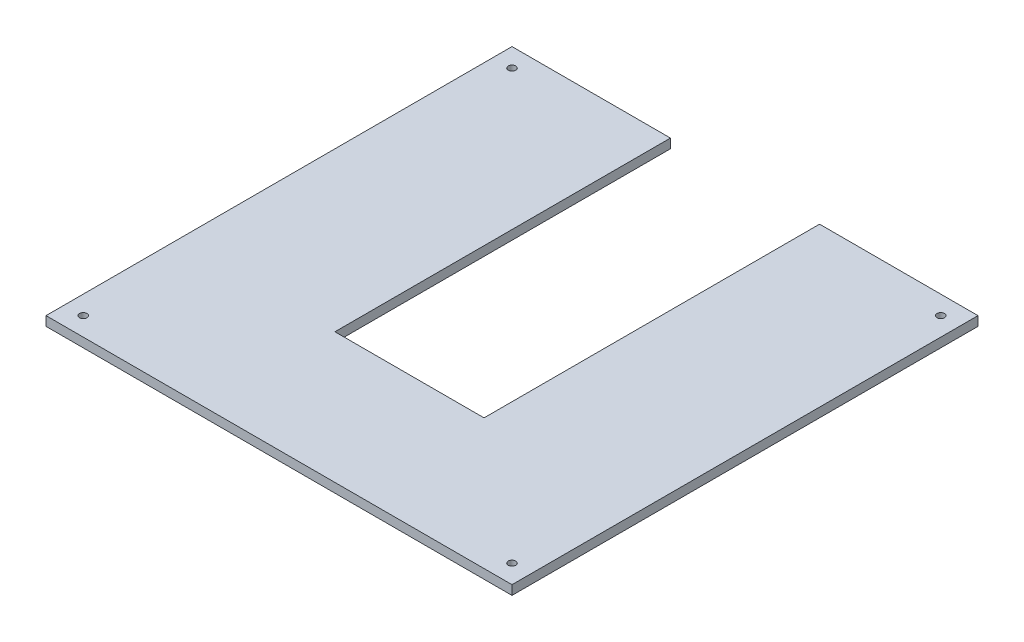
from build123d import *

# Parameters (mm, degrees)
ESBO_O1_R                = 2
RESSALTO_EXTRUS_O1_DEPTH = 5


with BuildPart() as part:
    # Esboço1 → Ressalto-extrusão1 (new body)
    with BuildSketch(Plane(origin=(0, 0, 0), x_dir=(1, 0, 0), z_dir=(0, 1, 0))):
        Polygon((-125, 125), (-40, 125), (-40, -55), (40, -55), (40, 125), (125, 125), (125, -125), (-125, -125), align=None)
        with Locations((-115, 115)):
            Circle(ESBO_O1_R, mode=Mode.SUBTRACT)
        with Locations((115, 115)):
            Circle(ESBO_O1_R, mode=Mode.SUBTRACT)
        with Locations((-115, -115)):
            Circle(ESBO_O1_R, mode=Mode.SUBTRACT)
        with Locations((115, -115)):
            Circle(ESBO_O1_R, mode=Mode.SUBTRACT)
    extrude(amount=RESSALTO_EXTRUS_O1_DEPTH)


solid = part.part
